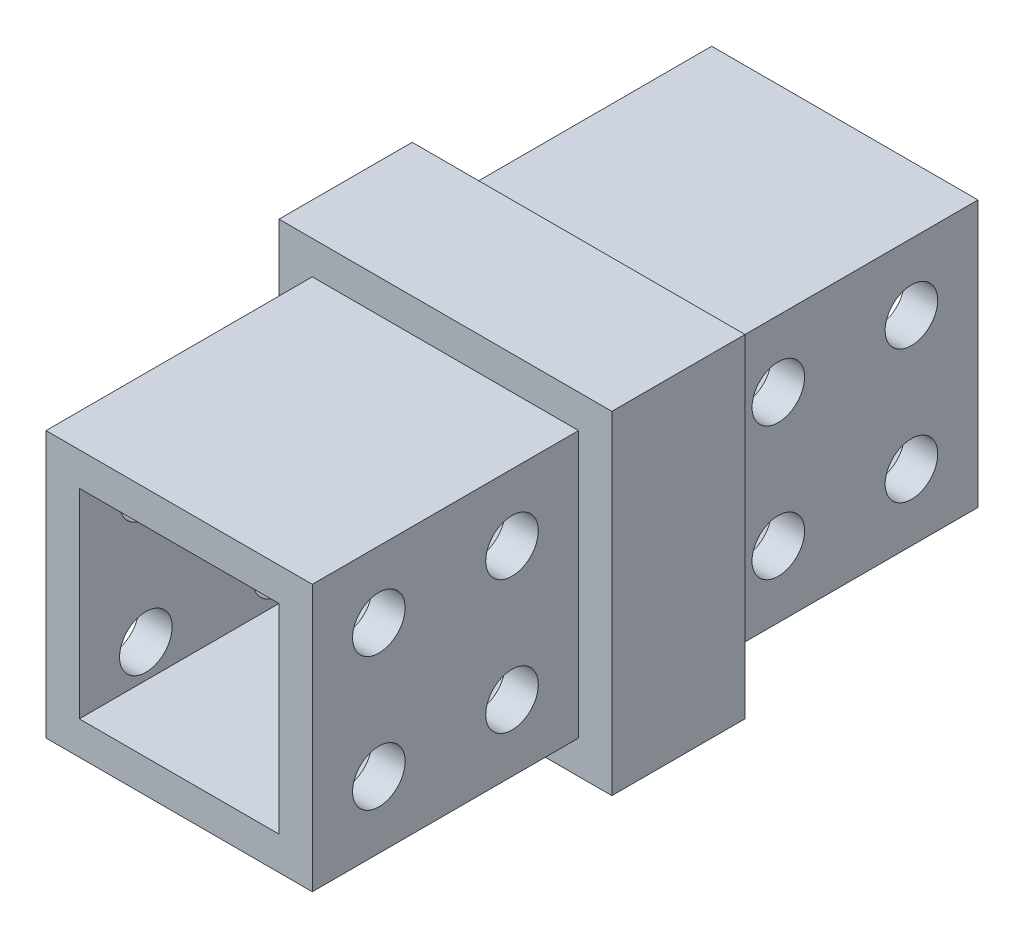
from build123d import *

# Parameters (mm, degrees)
SKETCH1_W           = 25.4
SKETCH1_H           = 25.4
BOSS_EXTRUDE1_DEPTH = 25.4
SKETCH2_W           = 31.75
SKETCH2_H           = 31.75
BOSS_EXTRUDE2_DEPTH = 12.7
SKETCH3_W           = 25.4
SKETCH3_H           = 25.4
BOSS_EXTRUDE3_DEPTH = 25.4
SKETCH4_R           = 2.50825
CUT_EXTRUDE2_DEPTH  = 25.4
SKETCH5_W           = 19.05
SKETCH5_H           = 19.05
CUT_EXTRUDE3_DEPTH  = 63.5


with BuildPart() as part:
    # Sketch1 → Boss-Extrude1 (new body)
    with BuildSketch(Plane.XY):
        with Locations((-12.7, -12.7)):
            Rectangle(SKETCH1_W, SKETCH1_H)
    extrude(amount=BOSS_EXTRUDE1_DEPTH)

    # Sketch2 → Boss-Extrude2 (add)
    with BuildSketch(Plane.XY.offset(25.4)):
        with Locations((-12.7, -12.7)):
            Rectangle(SKETCH2_W, SKETCH2_H)
    extrude(amount=BOSS_EXTRUDE2_DEPTH)

    # Sketch3 → Boss-Extrude3 (add)
    with BuildSketch(Plane.XY.offset(38.1)):
        with Locations((-12.7, -12.7)):
            Rectangle(SKETCH3_W, SKETCH3_H)
    extrude(amount=BOSS_EXTRUDE3_DEPTH)

    # Sketch4 → Cut-Extrude2 (cut)
    with BuildSketch(Plane(origin=(0, 0, 0), x_dir=(0, 0, -1), z_dir=(1, 0, 0))):
        with Locations((-57.15, -6.35)):
            Circle(SKETCH4_R)
        with Locations((-44.45, -6.35)):
            Circle(SKETCH4_R)
        with Locations((-57.15, -19.05)):
            Circle(SKETCH4_R)
        with Locations((-44.45, -19.05)):
            Circle(SKETCH4_R)
    cut_extrude2 = extrude(amount=-CUT_EXTRUDE2_DEPTH, mode=Mode.SUBTRACT)

    # Sketch5 → Cut-Extrude3 (cut)
    with BuildSketch(Plane.XY.offset(63.5)):
        with Locations((-12.7, -12.7)):
            Rectangle(SKETCH5_W, SKETCH5_H)
    extrude(amount=-CUT_EXTRUDE3_DEPTH, mode=Mode.SUBTRACT)

    # Mirror1: Cut-Extrude2 across plane
    add(cut_extrude2.mirror(Plane.XY.offset(31.75)), mode=Mode.SUBTRACT)


solid = part.part
